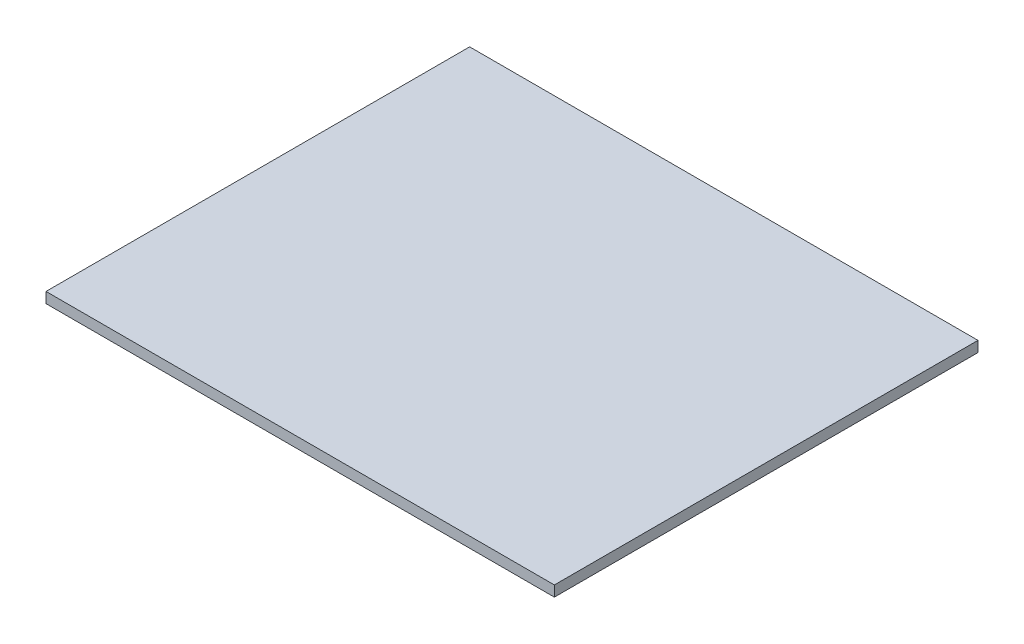
from build123d import *

# Parameters (mm, degrees)
SKETCH1_W           = 152.4
SKETCH1_H           = 127
BOSS_EXTRUDE1_DEPTH = 3.175


with BuildPart() as part:
    # Sketch1 → Boss-Extrude1 (new body)
    with BuildSketch(Plane(origin=(0, 0, 0), x_dir=(1, 0, 0), z_dir=(0, 1, 0))):
        Rectangle(SKETCH1_W, SKETCH1_H)
    extrude(amount=BOSS_EXTRUDE1_DEPTH)


solid = part.part
